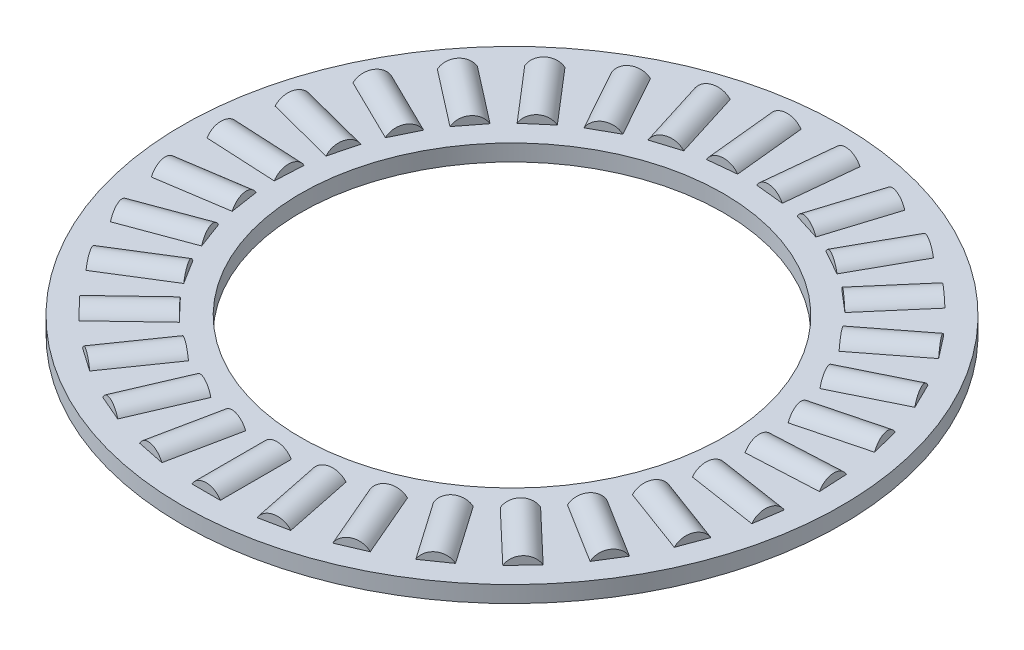
from build123d import *

# Parameters (mm, degrees)
SKETCH5_W         = 7.11835
SKETCH5_H         = 0.9921875
SKETCH3_W         = 4.27101
SKETCH3_H         = 0.9921875
SKETCH2_W         = 4.27101
SKETCH2_H         = 0.9921875
CIRPATTERN1_COUNT = 31
CIRPATTERN2_COUNT = 31


with BuildPart() as part:
    # Sketch5 → Revolve3 (revolve)
    with BuildSketch(Plane(origin=(0, 0, 0), x_dir=(0, 0, -1), z_dir=(1, 0, 0)), mode=Mode.PRIVATE) as revolve3_sk:
        with Locations((-16.284575, 0)):
            Rectangle(SKETCH5_W, SKETCH5_H)
    revolve(revolve3_sk.sketch.rotate(Axis((0, -0.9921875, 0), (0, 1, 0)), 180), axis=Axis((0, -0.9921875, 0), (0, 1, 0)))

    # Sketch3 → Cut-Revolve1 (revolve, cut)
    with BuildSketch(Plane(origin=(0, 0, 0), x_dir=(0, 0, -1), z_dir=(1, 0, 0))):
        with Locations((-16.284575, 0.49609375)):
            Rectangle(SKETCH3_W, SKETCH3_H)
    cut_revolve1 = revolve(axis=Axis((0, 0, 18.42008), (0, 0, -1)), mode=Mode.SUBTRACT)

    # CirPattern2: Cut-Revolve1 ×31 about axis
    cirpattern2_axis = Axis((0, 0, 0), (0, 1, 0))
    for i in range(1, CIRPATTERN2_COUNT):
        add(cut_revolve1.rotate(cirpattern2_axis, i * 360 / CIRPATTERN2_COUNT), mode=Mode.SUBTRACT)


with BuildPart() as body_2:
    # Sketch2 → Revolve2 (revolve)
    with BuildSketch(Plane(origin=(0, 0, 0), x_dir=(0, 0, -1), z_dir=(1, 0, 0)), mode=Mode.PRIVATE) as revolve2_sk:
        with Locations((-16.284575, 0.49609375)):
            Rectangle(SKETCH2_W, SKETCH2_H)
    revolve(revolve2_sk.sketch.rotate(Axis((0, 0, 18.42008), (0, 0, -1)), 90), axis=Axis((0, 0, 18.42008), (0, 0, -1)))


with BuildPart() as cirpattern1_1:
    # CirPattern1: pattern copy
    add(body_2.part.rotate(Axis((0, 0, 0), (0, 1, 0)), 1 * 360 / CIRPATTERN1_COUNT))


with BuildPart() as cirpattern1_2:
    # CirPattern1: pattern copy
    add(body_2.part.rotate(Axis((0, 0, 0), (0, 1, 0)), 2 * 360 / CIRPATTERN1_COUNT))


with BuildPart() as cirpattern1_3:
    # CirPattern1: pattern copy
    add(body_2.part.rotate(Axis((0, 0, 0), (0, 1, 0)), 3 * 360 / CIRPATTERN1_COUNT))


with BuildPart() as cirpattern1_4:
    # CirPattern1: pattern copy
    add(body_2.part.rotate(Axis((0, 0, 0), (0, 1, 0)), 4 * 360 / CIRPATTERN1_COUNT))


with BuildPart() as cirpattern1_5:
    # CirPattern1: pattern copy
    add(body_2.part.rotate(Axis((0, 0, 0), (0, 1, 0)), 5 * 360 / CIRPATTERN1_COUNT))


with BuildPart() as cirpattern1_6:
    # CirPattern1: pattern copy
    add(body_2.part.rotate(Axis((0, 0, 0), (0, 1, 0)), 6 * 360 / CIRPATTERN1_COUNT))


with BuildPart() as cirpattern1_7:
    # CirPattern1: pattern copy
    add(body_2.part.rotate(Axis((0, 0, 0), (0, 1, 0)), 7 * 360 / CIRPATTERN1_COUNT))


with BuildPart() as cirpattern1_8:
    # CirPattern1: pattern copy
    add(body_2.part.rotate(Axis((0, 0, 0), (0, 1, 0)), 8 * 360 / CIRPATTERN1_COUNT))


with BuildPart() as cirpattern1_9:
    # CirPattern1: pattern copy
    add(body_2.part.rotate(Axis((0, 0, 0), (0, 1, 0)), 9 * 360 / CIRPATTERN1_COUNT))


with BuildPart() as cirpattern1_10:
    # CirPattern1: pattern copy
    add(body_2.part.rotate(Axis((0, 0, 0), (0, 1, 0)), 10 * 360 / CIRPATTERN1_COUNT))


with BuildPart() as cirpattern1_11:
    # CirPattern1: pattern copy
    add(body_2.part.rotate(Axis((0, 0, 0), (0, 1, 0)), 11 * 360 / CIRPATTERN1_COUNT))


with BuildPart() as cirpattern1_12:
    # CirPattern1: pattern copy
    add(body_2.part.rotate(Axis((0, 0, 0), (0, 1, 0)), 12 * 360 / CIRPATTERN1_COUNT))


with BuildPart() as cirpattern1_13:
    # CirPattern1: pattern copy
    add(body_2.part.rotate(Axis((0, 0, 0), (0, 1, 0)), 13 * 360 / CIRPATTERN1_COUNT))


with BuildPart() as cirpattern1_14:
    # CirPattern1: pattern copy
    add(body_2.part.rotate(Axis((0, 0, 0), (0, 1, 0)), 14 * 360 / CIRPATTERN1_COUNT))


with BuildPart() as cirpattern1_15:
    # CirPattern1: pattern copy
    add(body_2.part.rotate(Axis((0, 0, 0), (0, 1, 0)), 15 * 360 / CIRPATTERN1_COUNT))


with BuildPart() as cirpattern1_16:
    # CirPattern1: pattern copy
    add(body_2.part.rotate(Axis((0, 0, 0), (0, 1, 0)), 16 * 360 / CIRPATTERN1_COUNT))


with BuildPart() as cirpattern1_17:
    # CirPattern1: pattern copy
    add(body_2.part.rotate(Axis((0, 0, 0), (0, 1, 0)), 17 * 360 / CIRPATTERN1_COUNT))


with BuildPart() as cirpattern1_18:
    # CirPattern1: pattern copy
    add(body_2.part.rotate(Axis((0, 0, 0), (0, 1, 0)), 18 * 360 / CIRPATTERN1_COUNT))


with BuildPart() as cirpattern1_19:
    # CirPattern1: pattern copy
    add(body_2.part.rotate(Axis((0, 0, 0), (0, 1, 0)), 19 * 360 / CIRPATTERN1_COUNT))


with BuildPart() as cirpattern1_20:
    # CirPattern1: pattern copy
    add(body_2.part.rotate(Axis((0, 0, 0), (0, 1, 0)), 20 * 360 / CIRPATTERN1_COUNT))


with BuildPart() as cirpattern1_21:
    # CirPattern1: pattern copy
    add(body_2.part.rotate(Axis((0, 0, 0), (0, 1, 0)), 21 * 360 / CIRPATTERN1_COUNT))


with BuildPart() as cirpattern1_22:
    # CirPattern1: pattern copy
    add(body_2.part.rotate(Axis((0, 0, 0), (0, 1, 0)), 22 * 360 / CIRPATTERN1_COUNT))


with BuildPart() as cirpattern1_23:
    # CirPattern1: pattern copy
    add(body_2.part.rotate(Axis((0, 0, 0), (0, 1, 0)), 23 * 360 / CIRPATTERN1_COUNT))


with BuildPart() as cirpattern1_24:
    # CirPattern1: pattern copy
    add(body_2.part.rotate(Axis((0, 0, 0), (0, 1, 0)), 24 * 360 / CIRPATTERN1_COUNT))


with BuildPart() as cirpattern1_25:
    # CirPattern1: pattern copy
    add(body_2.part.rotate(Axis((0, 0, 0), (0, 1, 0)), 25 * 360 / CIRPATTERN1_COUNT))


with BuildPart() as cirpattern1_26:
    # CirPattern1: pattern copy
    add(body_2.part.rotate(Axis((0, 0, 0), (0, 1, 0)), 26 * 360 / CIRPATTERN1_COUNT))


with BuildPart() as cirpattern1_27:
    # CirPattern1: pattern copy
    add(body_2.part.rotate(Axis((0, 0, 0), (0, 1, 0)), 27 * 360 / CIRPATTERN1_COUNT))


with BuildPart() as cirpattern1_28:
    # CirPattern1: pattern copy
    add(body_2.part.rotate(Axis((0, 0, 0), (0, 1, 0)), 28 * 360 / CIRPATTERN1_COUNT))


with BuildPart() as cirpattern1_29:
    # CirPattern1: pattern copy
    add(body_2.part.rotate(Axis((0, 0, 0), (0, 1, 0)), 29 * 360 / CIRPATTERN1_COUNT))


with BuildPart() as cirpattern1_30:
    # CirPattern1: pattern copy
    add(body_2.part.rotate(Axis((0, 0, 0), (0, 1, 0)), 30 * 360 / CIRPATTERN1_COUNT))


solid = Compound([part.part, body_2.part, cirpattern1_1.part, cirpattern1_2.part, cirpattern1_3.part, cirpattern1_4.part, cirpattern1_5.part, cirpattern1_6.part, cirpattern1_7.part, cirpattern1_8.part, cirpattern1_9.part, cirpattern1_10.part, cirpattern1_11.part, cirpattern1_12.part, cirpattern1_13.part, cirpattern1_14.part, cirpattern1_15.part, cirpattern1_16.part, cirpattern1_17.part, cirpattern1_18.part, cirpattern1_19.part, cirpattern1_20.part, cirpattern1_21.part, cirpattern1_22.part, cirpattern1_23.part, cirpattern1_24.part, cirpattern1_25.part, cirpattern1_26.part, cirpattern1_27.part, cirpattern1_28.part, cirpattern1_29.part, cirpattern1_30.part])
